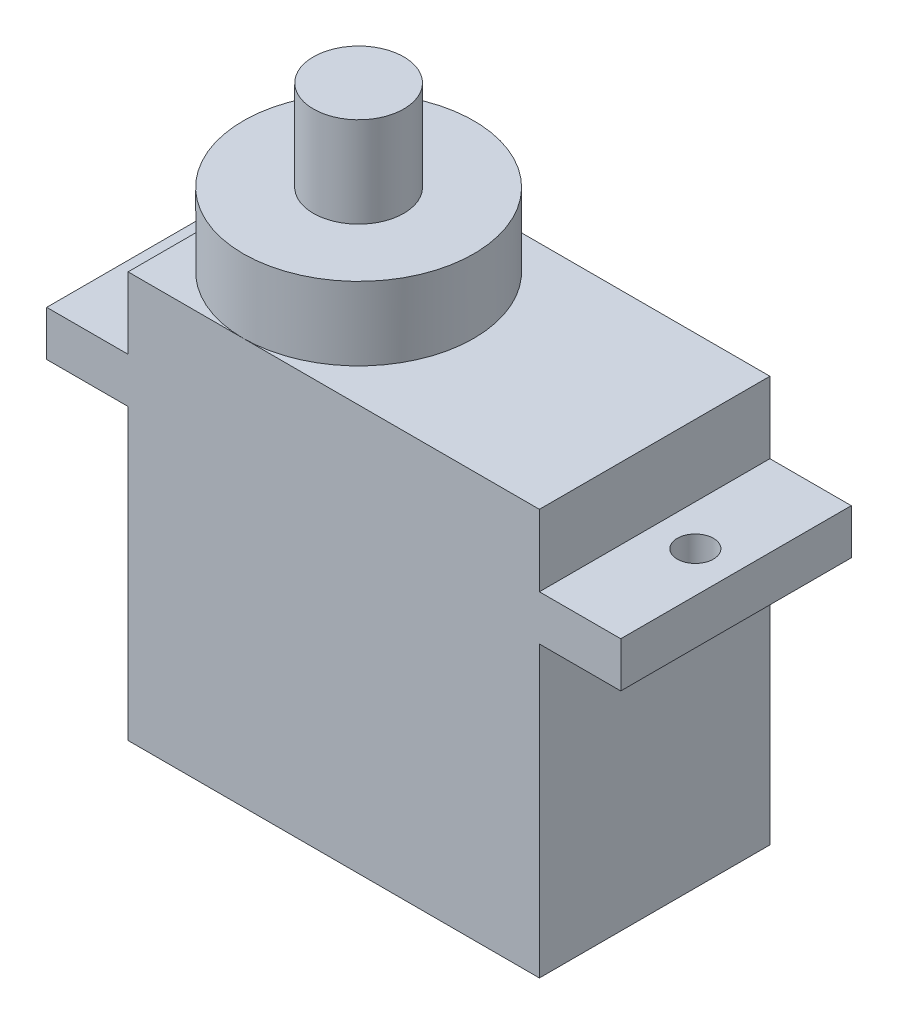
from build123d import *

# Parameters (mm, degrees)
SKETCH1_W           = 22.75
SKETCH1_H           = 22.45
BOSS_EXTRUDE1_DEPTH = 12.75
SKETCH2_W           = 12.75
SKETCH2_H           = 2.5
BOSS_EXTRUDE2_DEPTH = 4.5
SKETCH3_W           = 12.75
SKETCH3_H           = 2.5
BOSS_EXTRUDE3_DEPTH = 4.5
SKETCH4_R           = 1
CUT_EXTRUDE1_DEPTH  = 2.5
SKETCH5_R           = 1
CUT_EXTRUDE2_DEPTH  = 2.5
SKETCH6_R           = 6.375
BOSS_EXTRUDE4_DEPTH = 4.05
SKETCH7_R           = 2.5
BOSS_EXTRUDE5_DEPTH = 5


with BuildPart() as part:
    # Sketch1 → Boss-Extrude1 (new body)
    with BuildSketch(Plane.XY):
        with Locations((3.479135338, 0)):
            Rectangle(SKETCH1_W, SKETCH1_H)
    extrude(amount=BOSS_EXTRUDE1_DEPTH)

    # Sketch2 → Boss-Extrude2 (add)
    with BuildSketch(Plane(origin=(14.854135338, 0, 0), x_dir=(0, 0, -1), z_dir=(1, 0, 0))):
        with Locations((-6.375, 6.025)):
            Rectangle(SKETCH2_W, SKETCH2_H)
    extrude(amount=BOSS_EXTRUDE2_DEPTH)

    # Sketch3 → Boss-Extrude3 (add)
    with BuildSketch(Plane.ZY.offset(7.895864662)):
        with Locations((6.375, 6.025)):
            Rectangle(SKETCH3_W, SKETCH3_H)
    extrude(amount=BOSS_EXTRUDE3_DEPTH)

    # Sketch4 → Cut-Extrude1 (cut)
    with BuildSketch(Plane(origin=(0, 7.275, 0), x_dir=(1, 0, 0), z_dir=(0, 1, 0))):
        with Locations((-10.145864662, -6.375)):
            Circle(SKETCH4_R)
    extrude(amount=-CUT_EXTRUDE1_DEPTH, mode=Mode.SUBTRACT)

    # Sketch5 → Cut-Extrude2 (cut)
    with BuildSketch(Plane(origin=(0, 7.275, 0), x_dir=(1, 0, 0), z_dir=(0, 1, 0))):
        with Locations((17.104135338, -6.375)):
            Circle(SKETCH5_R)
    extrude(amount=-CUT_EXTRUDE2_DEPTH, mode=Mode.SUBTRACT)

    # Sketch6 → Boss-Extrude4 (add)
    with BuildSketch(Plane(origin=(0, 11.225, 0), x_dir=(1, 0, 0), z_dir=(0, 1, 0))):
        with Locations((-1.520864662, -6.375)):
            Circle(SKETCH6_R)
    extrude(amount=BOSS_EXTRUDE4_DEPTH)

    # Sketch7 → Boss-Extrude5 (add)
    with BuildSketch(Plane(origin=(0, 15.275, 0), x_dir=(1, 0, 0), z_dir=(0, 1, 0))):
        with Locations((-1.520864662, -6.375)):
            Circle(SKETCH7_R)
    extrude(amount=BOSS_EXTRUDE5_DEPTH)


solid = part.part
